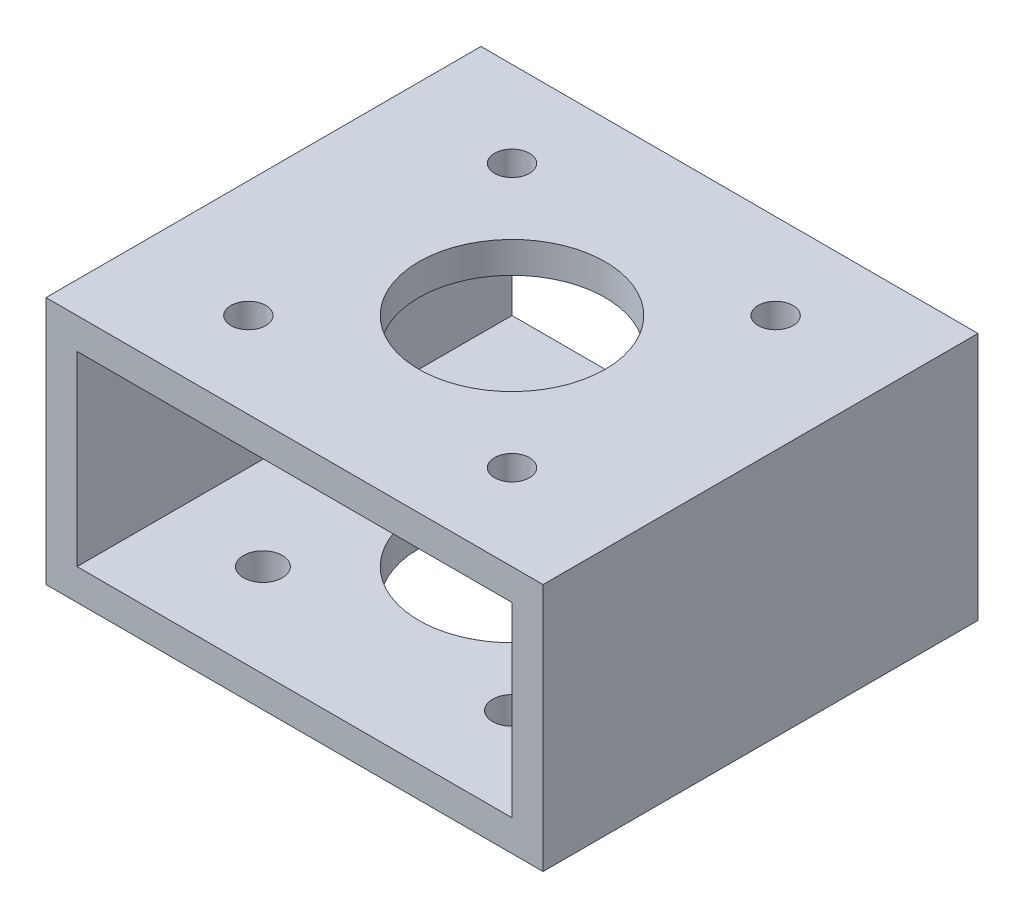
from build123d import *

# Parameters (mm, degrees)
SKETCH1_W                           = 50.8
SKETCH1_H                           = 25.4
BOSS_EXTRUDE1_DEPTH                 = 22.225
SKETCH2_R                           = 9.525
CUT_EXTRUDE1_DEPTH                  = 26.4
SKETCH4_W                           = 44.45
SKETCH4_H                           = 19.05
CUT_EXTRUDE3_DEPTH                  = 45.45
F_9_64_0_14063_DIAMETER_HOLE2_D     = 3.572002
F_9_64_0_14063_DIAMETER_HOLE2_DEPTH = 3.175
F_5_32_0_15625_DIAMETER_HOLE1_D     = 3.96875
F_5_32_0_15625_DIAMETER_HOLE1_DEPTH = 3.175


with BuildPart() as part:
    # Sketch1 → Boss-Extrude1 (new body, symmetric)
    with BuildSketch(Plane.XY):
        with Locations((0, 12.7)):
            Rectangle(SKETCH1_W, SKETCH1_H)
    extrude(amount=BOSS_EXTRUDE1_DEPTH, both=True)

    # Sketch2 → Cut-Extrude1 (cut, through all)
    with BuildSketch(Plane(origin=(0, 25.4, 0), x_dir=(1, 0, 0), z_dir=(0, 1, 0))):
        Circle(SKETCH2_R)
    extrude(amount=-CUT_EXTRUDE1_DEPTH, mode=Mode.SUBTRACT)

    # Sketch4 → Cut-Extrude3 (cut, through all)
    with BuildSketch(Plane(origin=(0, 0, -22.225), x_dir=(-1, 0, 0), z_dir=(0, 0, -1))):
        with Locations((0, 12.7)):
            Rectangle(SKETCH4_W, SKETCH4_H)
    extrude(amount=-CUT_EXTRUDE3_DEPTH, mode=Mode.SUBTRACT)

    # 9/64 (0.14063) Diameter Hole2
    with Locations(Plane(origin=(0, 25.4, 0), x_dir=(1, 0, 0), z_dir=(0, 1, 0))):
        with Locations((-13.470384182, 13.470384182), (13.470384182, 13.470384182), (13.470384182, -13.470384182), (-13.470384182, -13.470384182)):
            Hole(F_9_64_0_14063_DIAMETER_HOLE2_D / 2, depth=F_9_64_0_14063_DIAMETER_HOLE2_DEPTH)

    # 5/32 (0.15625) Diameter Hole1
    with Locations(Plane(origin=(0, 0, 0), x_dir=(-1, 0, 0), z_dir=(0, -1, 0))):
        with Locations((-12.727922061, 12.727922061), (12.727922061, 12.727922061), (12.727922061, -12.727922061), (-12.727922061, -12.727922061)):
            Hole(F_5_32_0_15625_DIAMETER_HOLE1_D / 2, depth=F_5_32_0_15625_DIAMETER_HOLE1_DEPTH)


solid = part.part
